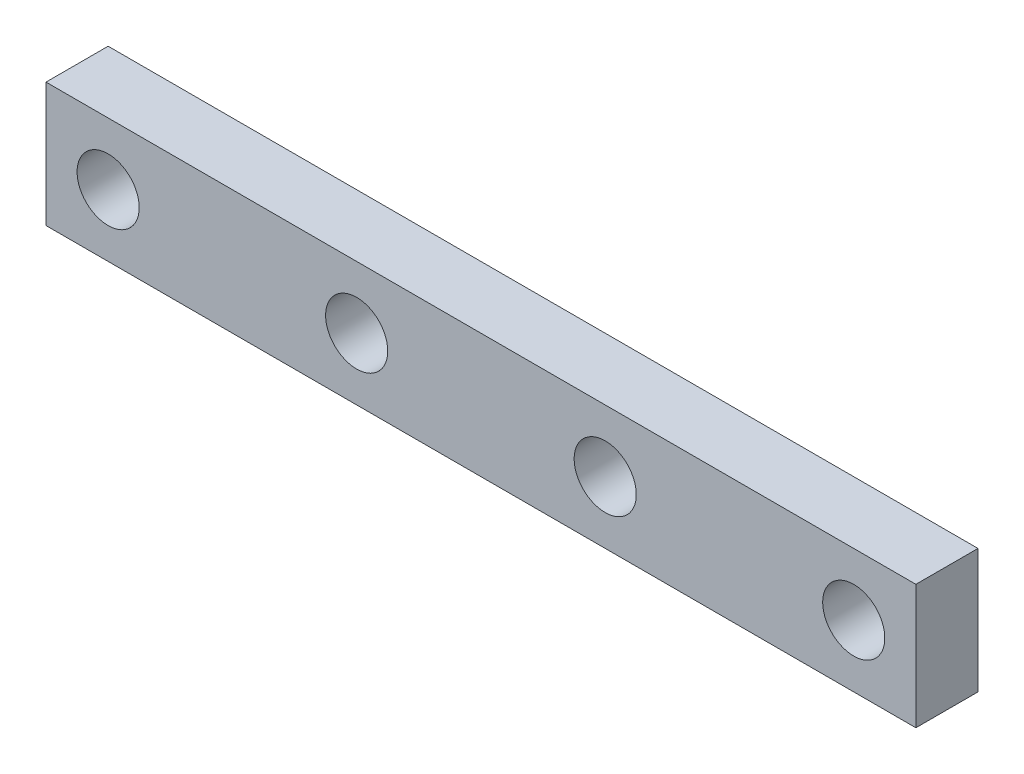
from build123d import *

# Parameters (mm, degrees)
SKETCH2_W           = 44.45
SKETCH2_H           = 6.35
BOSS_EXTRUDE1_DEPTH = 3.175
SKETCH3_R           = 1.5875
CUT_EXTRUDE1_DEPTH  = 4.175


with BuildPart() as part:
    # Sketch2 → Boss-Extrude1 (new body)
    with BuildSketch(Plane.XY):
        Rectangle(SKETCH2_W, SKETCH2_H)
    extrude(amount=BOSS_EXTRUDE1_DEPTH)

    # Sketch3 → Cut-Extrude1 (cut, through all)
    with BuildSketch(Plane.XY.offset(3.175)):
        with Locations((-6.35, 0)):
            Circle(SKETCH3_R)
        with Locations((-19.05, 0)):
            Circle(SKETCH3_R)
    cut_extrude1 = extrude(amount=-CUT_EXTRUDE1_DEPTH, mode=Mode.SUBTRACT)

    # Mirror1: Cut-Extrude1 across plane
    add(cut_extrude1.mirror(Plane(origin=(0, 0, 0), x_dir=(0, 0, 1), z_dir=(1, 0, 0))), mode=Mode.SUBTRACT)


solid = part.part
